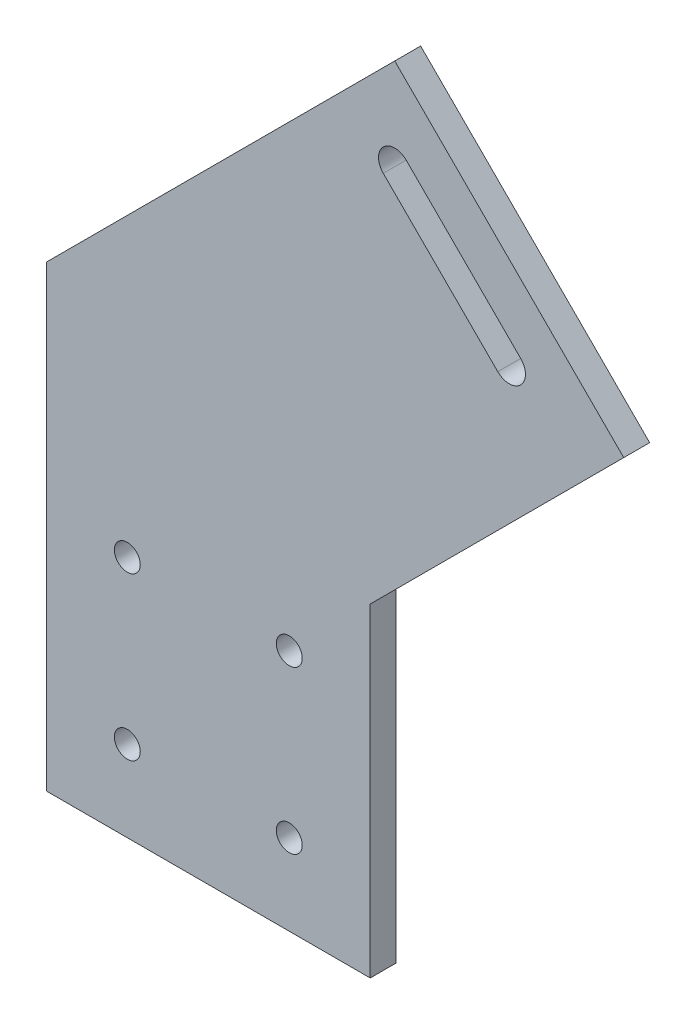
from build123d import *

# Parameters (mm, degrees)
SKETCH1_R           = 2
BOSS_EXTRUDE1_DEPTH = 4


with BuildPart() as part:
    # Sketch1 → Boss-Extrude1 (new body)
    with BuildSketch(Plane.XY):
        Polygon((28.783278196, 114.493956315), (64.138617256, 79.138617256), (25, 40), (25, -10), (-25, -10), (-25, 40), (-25, 60.710678119), align=None)
        with Locations((-12.5, 27.5)):
            Circle(SKETCH1_R, mode=Mode.SUBTRACT)
        with Locations((12.5, 27.5)):
            Circle(SKETCH1_R, mode=Mode.SUBTRACT)
        with Locations((12.5, 2.5)):
            Circle(SKETCH1_R, mode=Mode.SUBTRACT)
        with Locations((-12.5, 2.5)):
            Circle(SKETCH1_R, mode=Mode.SUBTRACT)
        with BuildLine():
            Line((48.228714679, 84.441918115), (30.551045149, 102.119587644))
            ThreePointArc((30.551045149, 102.119587644), (27.015511244, 102.119587644), (27.015511244, 98.584053738))
            Line((27.015511244, 98.584053738), (44.693180773, 80.906384209))
            ThreePointArc((44.693180773, 80.906384209), (48.228714679, 80.906384209), (48.228714679, 84.441918115))
        make_face(mode=Mode.SUBTRACT)
    extrude(amount=BOSS_EXTRUDE1_DEPTH)


solid = part.part
